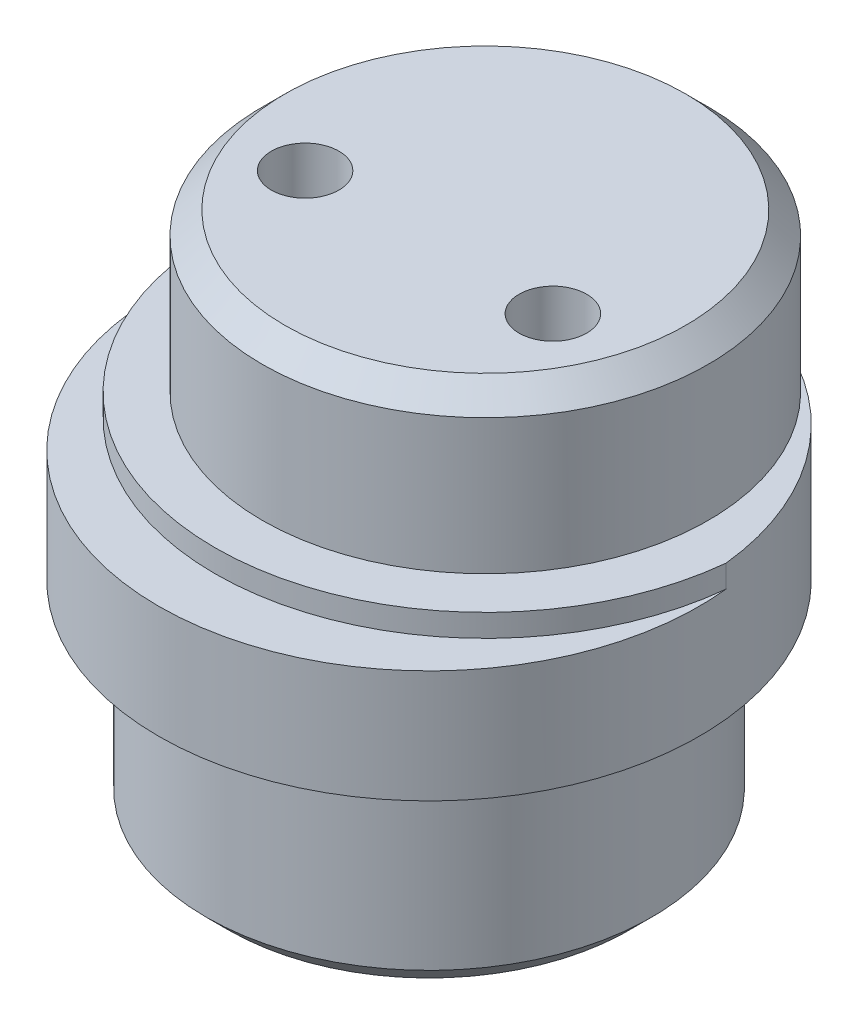
from build123d import *

# Parameters (mm, degrees)
SKETCH1_R           = 9.9
BOSS_EXTRUDE1_DEPTH = 9
SKETCH2_R           = 12
BOSS_EXTRUDE2_DEPTH = 6
SKETCH3_R           = 9.9
BOSS_EXTRUDE3_DEPTH = 7
SKETCH7_R           = 15
SKETCH7_R_2         = 12
CUT_EXTRUDE3_DEPTH  = 1
SKETCH10_R          = 1.5
CUT_EXTRUDE4_DEPTH  = 23
SKETCH12_R          = 1.5
CUT_EXTRUDE5_DEPTH  = 12
CHAMFER1_SIZE       = 1


with BuildPart() as part:
    # Sketch1 → Boss-Extrude1 (new body)
    with BuildSketch(Plane(origin=(0, 0, 0), x_dir=(1, 0, 0), z_dir=(0, 1, 0))):
        Circle(SKETCH1_R)
    extrude(amount=BOSS_EXTRUDE1_DEPTH)

    # Sketch2 → Boss-Extrude2 (add)
    with BuildSketch(Plane(origin=(0, 9, 0), x_dir=(1, 0, 0), z_dir=(0, 1, 0))):
        Circle(SKETCH2_R)
    extrude(amount=BOSS_EXTRUDE2_DEPTH)

    # Sketch3 → Boss-Extrude3 (add)
    with BuildSketch(Plane(origin=(0, 15, 0), x_dir=(1, 0, 0), z_dir=(0, 1, 0))):
        with Locations((0, 2.5)):
            Circle(SKETCH3_R)
    extrude(amount=BOSS_EXTRUDE3_DEPTH)

    # Sketch7 → Cut-Extrude3 (cut)
    with BuildSketch(Plane(origin=(0, 15, 0), x_dir=(1, 0, 0), z_dir=(0, 1, 0))):
        with Locations((0, 2.5)):
            Circle(SKETCH7_R)
        with Locations((0, 2.5)):
            Circle(SKETCH7_R_2, mode=Mode.SUBTRACT)
    extrude(amount=-CUT_EXTRUDE3_DEPTH, mode=Mode.SUBTRACT)

    # Sketch10 → Cut-Extrude4 (cut, through all)
    with BuildSketch(Plane(origin=(0, 22, 0), x_dir=(1, 0, 0), z_dir=(0, 1, 0))):
        with Locations((5.5, 0)):
            Circle(SKETCH10_R)
        with Locations((-5.5, 0)):
            Circle(SKETCH10_R)
    extrude(amount=-CUT_EXTRUDE4_DEPTH, mode=Mode.SUBTRACT)

    # Sketch12 → Cut-Extrude5 (cut)
    with BuildSketch(Plane(origin=(0, 0, 0), x_dir=(-1, 0, 0), z_dir=(0, -1, 0))):
        with Locations((0, 5.5)):
            Circle(SKETCH12_R)
        with Locations((0, -5.5)):
            Circle(SKETCH12_R)
    extrude(amount=-CUT_EXTRUDE5_DEPTH, mode=Mode.SUBTRACT)

    # Chamfer1
    chamfer1_edges = [part.edges().sort_by_distance(p)[0] for p in [
        (-9.9, 22, -2.5),
        (-9.9, 0, 0),
    ]]
    chamfer(chamfer1_edges, length=CHAMFER1_SIZE)


solid = part.part
